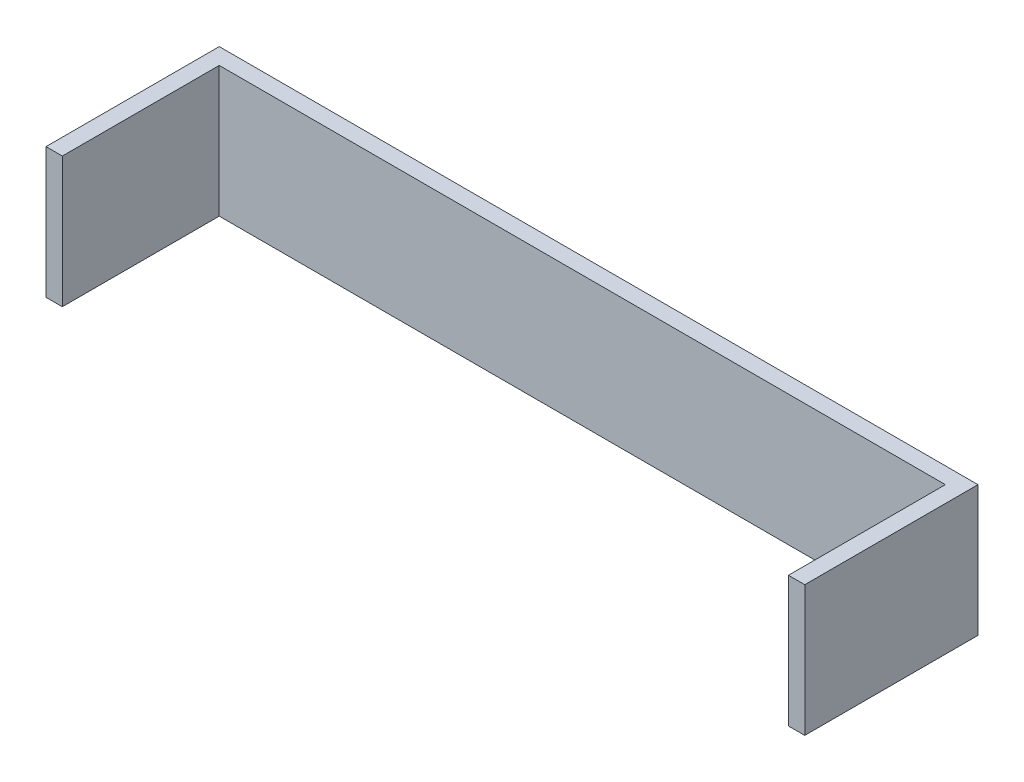
from build123d import *

# Parameters (mm, degrees)
SKETCH1_W           = 147.6375
SKETCH1_H           = 25.4
BOSS_EXTRUDE1_DEPTH = 3.175
SKETCH2_W           = 3.175
SKETCH2_H           = 25.4
BOSS_EXTRUDE2_DEPTH = 30.53588


with BuildPart() as part:
    # Sketch1 → Boss-Extrude1 (new body)
    with BuildSketch(Plane.XY):
        Rectangle(SKETCH1_W, SKETCH1_H)
    extrude(amount=BOSS_EXTRUDE1_DEPTH)

    # Sketch2 → Boss-Extrude2 (add)
    with BuildSketch(Plane.XY.offset(3.175)):
        with Locations((-72.23125, 0)):
            Rectangle(SKETCH2_W, SKETCH2_H)
    boss_extrude2 = extrude(amount=BOSS_EXTRUDE2_DEPTH)

    # Mirror1: Boss-Extrude2 across plane
    add(boss_extrude2.mirror(Plane(origin=(0, 0, 0), x_dir=(0, 0, 1), z_dir=(1, 0, 0))))


solid = part.part
